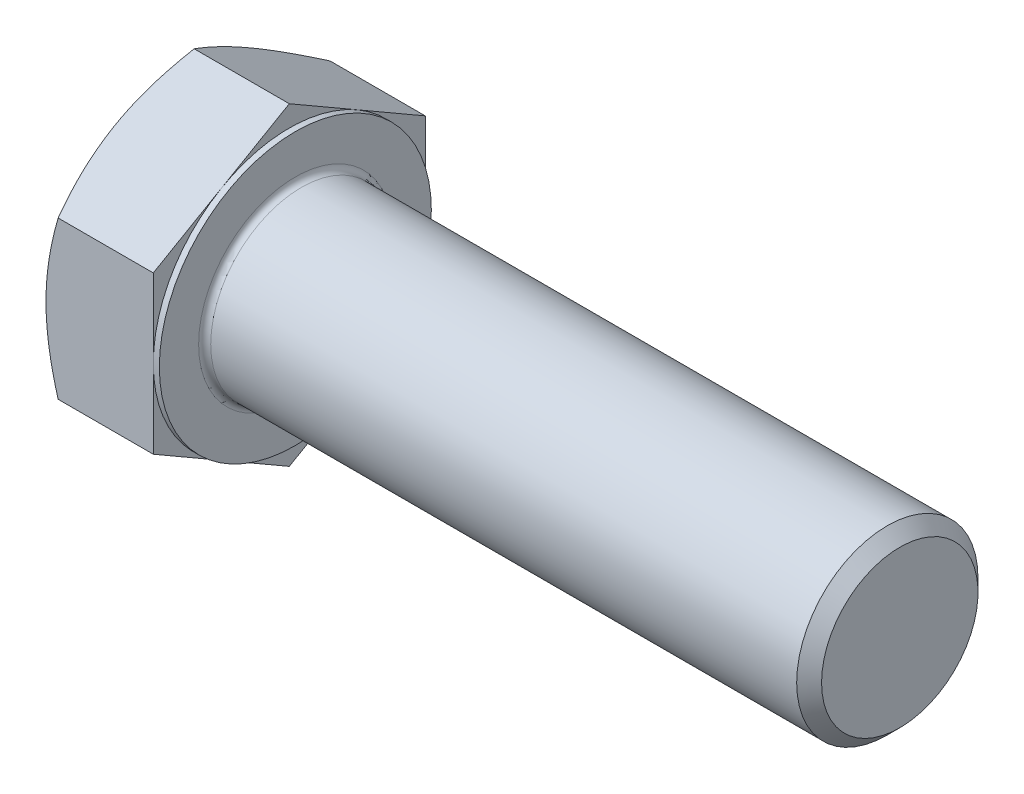
from build123d import *

# Parameters (mm, degrees)
BASEHEAD_DEPTH   = 15
BEARINGFACESKE_W = 0.8
BEARINGFACESKE_H = 2.784609691
FILLET_2_R       = 0.8


with BuildPart() as part:
    # BaseHeadSke → BaseHead (new body)
    with BuildSketch(Plane(origin=(0, 0, 0), x_dir=(0, 0, -1), z_dir=(1, 0, 0))):
        Polygon((18, 10.392304845), (0, 20.784609691), (-18, 10.392304845), (-18, -10.392304845), (0, -20.784609691), (18, -10.392304845), align=None)
    extrude(amount=BASEHEAD_DEPTH)

    # BodySke → BaseBody (revolve)
    with BuildSketch(Plane.XY):
        Polygon((0, 0), (95, 0), (95, 10.352), (93.352, 12), (0, 12), align=None)
    revolve(axis=Axis((0, 0, 0), (1, 0, 0)))

    # HeadChamferSke → HeadChamfer (revolve, cut)
    with BuildSketch(Plane.XY):
        Polygon((1.607695155, 20.784609691), (0, 20.784609691), (0, 18), align=None)
    revolve(axis=Axis((0, 0, 0), (1, 0, 0)), mode=Mode.SUBTRACT)

    # BearingFaceSke → BearingFace (revolve, cut)
    with BuildSketch(Plane.XY):
        with Locations((14.6, 19.392304845)):
            Rectangle(BEARINGFACESKE_W, BEARINGFACESKE_H)
    revolve(axis=Axis((0, 0, 0), (1, 0, 0)), mode=Mode.SUBTRACT)

    # Fillet 2
    fillet_2_edges = [part.edges().sort_by_distance(p)[0] for p in [
        (15, -12, 0),
    ]]
    fillet(fillet_2_edges, radius=FILLET_2_R)


solid = part.part
